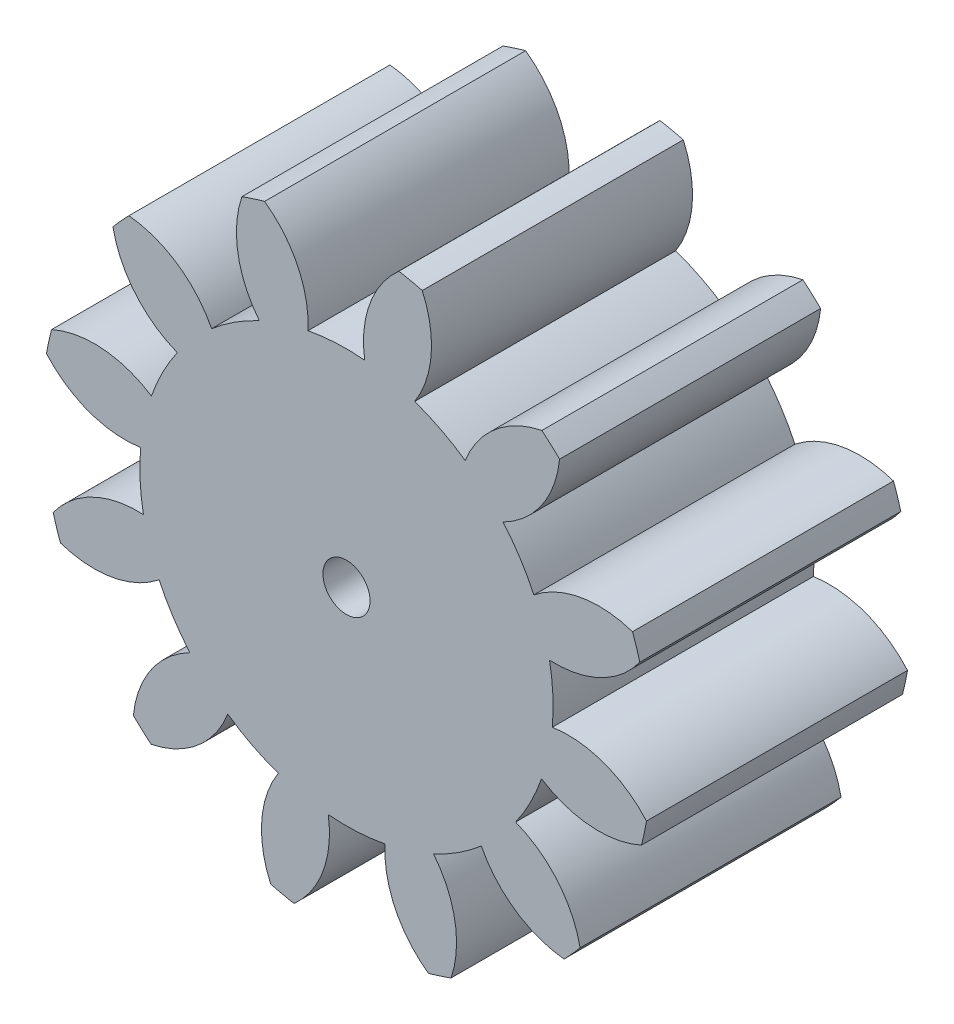
from build123d import *

# Parameters (mm, degrees)
SKETCH1_R           = 0.396875
BOSS_EXTRUDE1_DEPTH = 25.4
SKETCH3_R           = 2.29235
CUT_EXTRUDE1_DEPTH  = 45.3009


with BuildPart() as part:
    # Sketch1 → Boss-Extrude1 (new body)
    with BuildSketch(Plane(origin=(0, 0, 0), x_dir=(-1, 0, 0), z_dir=(0, 0, -1))):
        with BuildLine():
            ThreePointArc((-94.226399104, -28.701297083), (-93.354822314, -23.746772531), (-94.966890975, -18.98146097))
            ThreePointArc((-94.966890975, -18.98146097), (-92.421623219, -17.889980312), (-90.050475192, -16.459115183))
            ThreePointArc((-90.050475192, -16.459115183), (-87.119940237, -20.547993332), (-82.587097641, -22.729803966))
            ThreePointArc((-82.587097641, -22.729803966), (-81.710050828, -21.966437271), (-80.863625765, -21.169251948))
            ThreePointArc((-80.863625765, -21.169251948), (-82.5860804, -16.442719427), (-86.364828593, -13.121872888))
            ThreePointArc((-86.364828593, -13.121872888), (-84.706302386, -10.903989032), (-83.368260523, -8.479249468))
            ThreePointArc((-83.368260523, -8.479249468), (-78.785903731, -10.555054341), (-73.769441574, -10.178136478))
            ThreePointArc((-73.769441574, -10.178136478), (-73.391580101, -9.078518121), (-73.057147156, -7.964922849))
            ThreePointArc((-73.057147156, -7.964922849), (-76.912102887, -4.732852931), (-81.845018087, -3.746289563))
            ThreePointArc((-81.845018087, -3.746289563), (-81.517634186, -0.996282698), (-81.571225724, 1.772624294))
            ThreePointArc((-81.571225724, 1.772624294), (-76.564885896, 2.266102937), (-72.408961163, 5.10075446))
            ThreePointArc((-72.408961163, 5.10075446), (-72.631532707, 6.241982628), (-72.898702917, 7.373600896))
            ThreePointArc((-72.898702917, 7.373600896), (-77.853227469, 8.245177686), (-82.61853903, 6.633109025))
            ThreePointArc((-82.61853903, 6.633109025), (-83.710019688, 9.178376781), (-85.140884817, 11.549524808))
            ThreePointArc((-85.140884817, 11.549524808), (-81.052006668, 14.480059763), (-78.870196034, 19.012902359))
            ThreePointArc((-78.870196034, 19.012902359), (-79.633562729, 19.889949172), (-80.430748052, 20.736374235))
            ThreePointArc((-80.430748052, 20.736374235), (-85.157280573, 19.0139196), (-88.478127112, 15.235171407))
            ThreePointArc((-88.478127112, 15.235171407), (-90.696010968, 16.893697614), (-93.120750532, 18.231739477))
            ThreePointArc((-93.120750532, 18.231739477), (-91.044945659, 22.814096269), (-91.421863522, 27.830558426))
            ThreePointArc((-91.421863522, 27.830558426), (-92.521481879, 28.208419899), (-93.635077151, 28.542852844))
            ThreePointArc((-93.635077151, 28.542852844), (-96.867147069, 24.687897113), (-97.853710437, 19.754981913))
            ThreePointArc((-97.853710437, 19.754981913), (-100.603717302, 20.082365814), (-103.372624294, 20.028774276))
            ThreePointArc((-103.372624294, 20.028774276), (-103.866102937, 25.035114104), (-106.70075446, 29.191038837))
            ThreePointArc((-106.70075446, 29.191038837), (-107.841982628, 28.968467293), (-108.973600896, 28.701297083))
            ThreePointArc((-108.973600896, 28.701297083), (-109.845177686, 23.746772531), (-108.233109025, 18.98146097))
            ThreePointArc((-108.233109025, 18.98146097), (-110.778376781, 17.889980312), (-113.149524808, 16.459115183))
            ThreePointArc((-113.149524808, 16.459115183), (-116.080059763, 20.547993332), (-120.612902359, 22.729803966))
            ThreePointArc((-120.612902359, 22.729803966), (-121.489949172, 21.966437271), (-122.336374235, 21.169251948))
            ThreePointArc((-122.336374235, 21.169251948), (-120.6139196, 16.442719427), (-116.835171407, 13.121872888))
            ThreePointArc((-116.835171407, 13.121872888), (-118.493697614, 10.903989032), (-119.831739477, 8.479249468))
            ThreePointArc((-119.831739477, 8.479249468), (-124.414096269, 10.555054341), (-129.430558426, 10.178136478))
            ThreePointArc((-129.430558426, 10.178136478), (-129.808419899, 9.078518121), (-130.142852844, 7.964922849))
            ThreePointArc((-130.142852844, 7.964922849), (-126.287897113, 4.732852931), (-121.354981913, 3.746289563))
            ThreePointArc((-121.354981913, 3.746289563), (-121.682365814, 0.996282698), (-121.628774276, -1.772624294))
            ThreePointArc((-121.628774276, -1.772624294), (-126.635114104, -2.266102937), (-130.791038837, -5.10075446))
            ThreePointArc((-130.791038837, -5.10075446), (-130.568467293, -6.241982628), (-130.301297083, -7.373600896))
            ThreePointArc((-130.301297083, -7.373600896), (-125.346772531, -8.245177686), (-120.58146097, -6.633109025))
            ThreePointArc((-120.58146097, -6.633109025), (-119.489980312, -9.178376781), (-118.059115183, -11.549524808))
            ThreePointArc((-118.059115183, -11.549524808), (-122.147993332, -14.480059763), (-124.329803966, -19.012902359))
            ThreePointArc((-124.329803966, -19.012902359), (-123.566437271, -19.889949172), (-122.769251948, -20.736374235))
            ThreePointArc((-122.769251948, -20.736374235), (-118.042719427, -19.0139196), (-114.721872888, -15.235171407))
            ThreePointArc((-114.721872888, -15.235171407), (-112.503989032, -16.893697614), (-110.079249468, -18.231739477))
            ThreePointArc((-110.079249468, -18.231739477), (-112.155054341, -22.814096269), (-111.778136478, -27.830558426))
            ThreePointArc((-111.778136478, -27.830558426), (-110.678518121, -28.208419899), (-109.564922849, -28.542852844))
            ThreePointArc((-109.564922849, -28.542852844), (-106.332852931, -24.687897113), (-105.346289563, -19.754981913))
            ThreePointArc((-105.346289563, -19.754981913), (-102.596282698, -20.082365814), (-99.827375706, -20.028774276))
            ThreePointArc((-99.827375706, -20.028774276), (-99.333897063, -25.035114104), (-96.49924554, -29.191038837))
            ThreePointArc((-96.49924554, -29.191038837), (-95.358017372, -28.968467293), (-94.226399104, -28.701297083))
        make_face()
        with Locations((-101.6, 0)):
            Circle(SKETCH1_R, mode=Mode.SUBTRACT)
    extrude(amount=-BOSS_EXTRUDE1_DEPTH)

    # Sketch3 → Cut-Extrude1 (cut)
    with BuildSketch(Plane.XY.offset(25.4)):
        with Locations((101.6, 0)):
            Circle(SKETCH3_R)
    extrude(amount=-CUT_EXTRUDE1_DEPTH, mode=Mode.SUBTRACT)


solid = part.part
